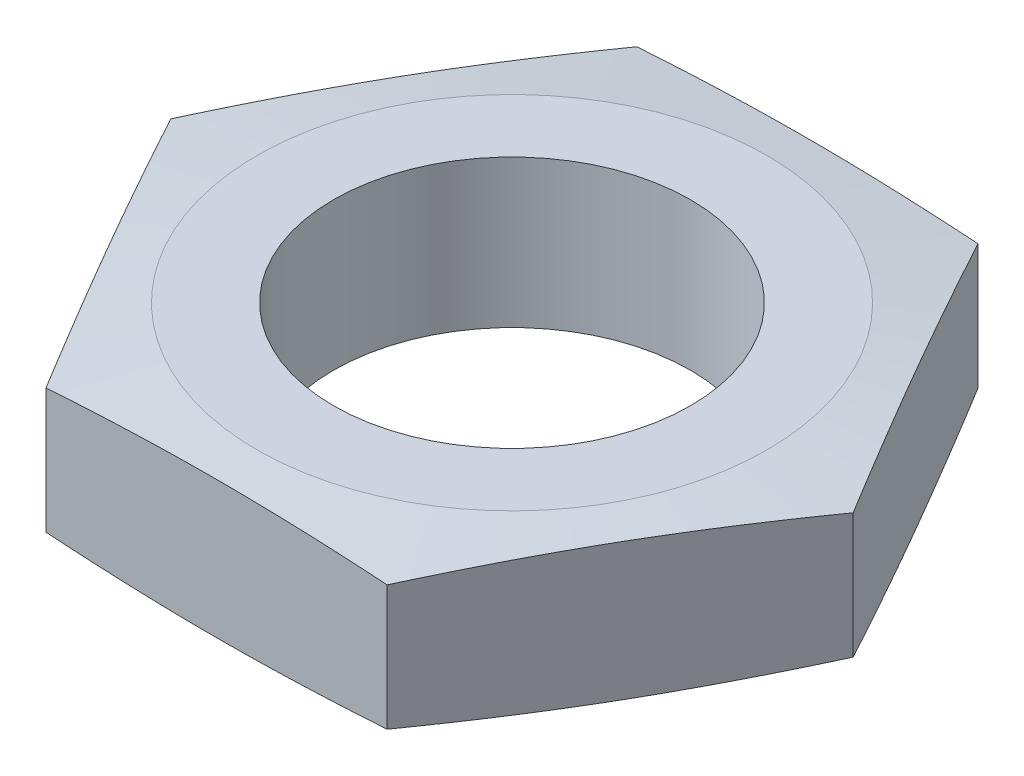
from build123d import *

# Parameters (mm, degrees)
BOSS_EXTRUDE1_DEPTH        = 6
M16X1_5_TAPPED_HOLE1_D     = 14.5
M16X1_5_TAPPED_HOLE1_DEPTH = 39.5
M16X1_5_TAPPED_HOLE1_TIP   = 4.356239488


with BuildPart() as part:
    # Sketch1 → Boss-Extrude1 (new body)
    with BuildSketch(Plane(origin=(0, 0, 0), x_dir=(1, 0, 0), z_dir=(0, 1, 0))):
        Polygon((6.92820323, 12), (-6.92820323, 12), (-13.856406461, 0), (-6.92820323, -12), (6.92820323, -12), (13.856406461, 0), align=None)
    extrude(amount=BOSS_EXTRUDE1_DEPTH)

    # Sketch2 → Cut-Revolve1 (revolve, cut)
    with BuildSketch(Plane.XY):
        Polygon((-13.856406461, 0), (-10.356406461, 0), (-13.856406461, 0.460783742), align=None)
        Polygon((-13.856406461, 6), (-10.356406461, 6), (-13.856406461, 5.539216258), align=None)
    revolve(axis=Axis((0, 0, 0), (0, 1, 0)), mode=Mode.SUBTRACT)

    # M16x1.5 Tapped Hole1
    with Locations(Plane(origin=(0, 6, 0), x_dir=(1, 0, 0), z_dir=(0, 1, 0))):
        with Locations((0, 0)):
            Hole(M16X1_5_TAPPED_HOLE1_D / 2, depth=M16X1_5_TAPPED_HOLE1_DEPTH)
            with Locations((0, 0, -(M16X1_5_TAPPED_HOLE1_DEPTH + M16X1_5_TAPPED_HOLE1_TIP / 2))):  # 118° drill point
                Cone(0, M16X1_5_TAPPED_HOLE1_D / 2, M16X1_5_TAPPED_HOLE1_TIP, mode=Mode.SUBTRACT)


solid = part.part
